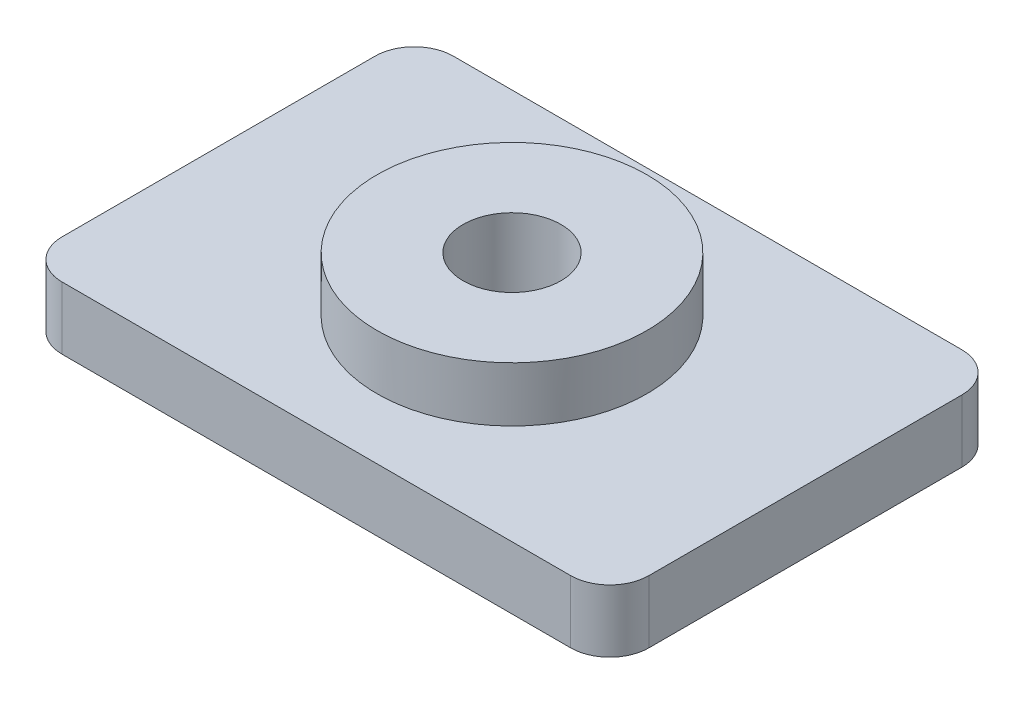
from build123d import *

# Parameters (mm, degrees)
SALIENTE_EXTRUIR1_DEPTH = 1.6
CROQUIS2_R              = 3.45
SALIENTE_EXTRUIR2_DEPTH = 1.4
CORTAR_EXTRUIR1_REACH   = 5
CROQUIS3_R              = 1.25


with BuildPart() as part:
    # Croquis1 → Saliente-Extruir1 (new body)
    with BuildSketch(Plane(origin=(0, 0, 0), x_dir=(1, 0, 0), z_dir=(0, 1, 0))):
        with BuildLine():
            Line((1, 0), (14, 0))
            ThreePointArc((14, 0), (14.707106781, 0.292893219), (15, 1))
            Line((15, 1), (15, 9))
            ThreePointArc((15, 9), (14.707106781, 9.707106781), (14, 10))
            Line((14, 10), (1, 10))
            ThreePointArc((1, 10), (0.292893219, 9.707106781), (0, 9))
            Line((0, 9), (0, 1))
            ThreePointArc((0, 1), (0.292893219, 0.292893219), (1, 0))
        make_face()
    extrude(amount=SALIENTE_EXTRUIR1_DEPTH)

    # Croquis2 → Saliente-Extruir2 (add)
    with BuildSketch(Plane(origin=(0, 1.6, 0), x_dir=(1, 0, 0), z_dir=(0, 1, 0))):
        with Locations((7.5, 5)):
            Circle(CROQUIS2_R)
    extrude(amount=SALIENTE_EXTRUIR2_DEPTH)

    # Croquis3 → Cortar-Extruir1 (cut, up to next)
    with BuildSketch(Plane(origin=(0, 3, 0), x_dir=(1, 0, 0), z_dir=(0, 1, 0)), mode=Mode.PRIVATE) as cortar_extruir1_sk1:
        with Locations((7.5, 5)):
            Circle(CROQUIS3_R)
    cortar_extruir1_tool1 = extrude(cortar_extruir1_sk1.sketch, amount=-CORTAR_EXTRUIR1_REACH, mode=Mode.PRIVATE) & part.part
    add(cortar_extruir1_tool1.solids().sort_by_distance((7.5, 3, -5))[0], mode=Mode.SUBTRACT)


solid = part.part
